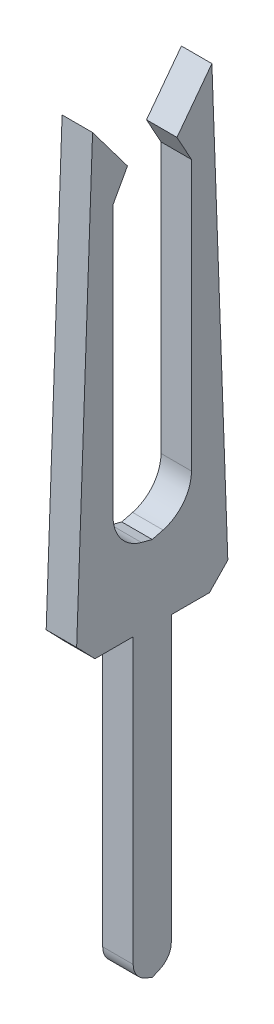
from build123d import *

# Parameters (mm, degrees)
BOSS_EXTRUDE1_DEPTH = 0.4


with BuildPart() as part:
    # Sketch1 → Boss-Extrude1 (new body)
    with BuildSketch(Plane(origin=(0, 0, 0), x_dir=(0, 0, -1), z_dir=(1, 0, 0))):
        with BuildLine():
            Line((-0.486576567, 7.906439428), (-0.277438328, 2.156274237))
            Line((-0.277438328, 2.156274237), (-0.518351631, 1.906439428))
            Line((-0.518351631, 1.906439428), (-1.019947879, 1.906439428))
            Line((-1.019947879, 1.906439428), (-1.019947879, -1.820037787))
            ThreePointArc((-1.019947879, -1.820037787), (-1.060356555, -1.956314993), (-1.168519693, -2.048537947))
            Line((-1.168519693, -2.048537947), (-1.269947879, -2.093560572))
            Line((-1.269947879, -2.093560572), (-1.371376066, -2.048537947))
            ThreePointArc((-1.371376066, -2.048537947), (-1.479539204, -1.956314993), (-1.519947879, -1.820037787))
            Line((-1.519947879, -1.820037787), (-1.519947879, 1.906439428))
            Line((-1.519947879, 1.906439428), (-2.021544128, 1.906439428))
            Line((-2.021544128, 1.906439428), (-2.26245743, 2.156274237))
            Line((-2.26245743, 2.156274237), (-2.053319191, 7.906439428))
            Line((-2.053319191, 7.906439428), (-1.594947879, 7.296916042))
            Line((-1.594947879, 7.296916042), (-1.785118415, 6.950118253))
            Line((-1.785118415, 6.950118253), (-1.785185155, 3.40759606))
            ThreePointArc((-1.785185155, 3.40759606), (-1.681017639, 3.102108908), (-1.411909463, 2.923912215))
            Line((-1.411909463, 2.923912215), (-1.269947879, 2.886717808))
            Line((-1.269947879, 2.886717808), (-1.127986296, 2.923912215))
            ThreePointArc((-1.127986296, 2.923912215), (-0.85887812, 3.102108908), (-0.754710604, 3.40759606))
            Line((-0.754710604, 3.40759606), (-0.754777344, 6.950118253))
            Line((-0.754777344, 6.950118253), (-0.944947879, 7.296916042))
            Line((-0.944947879, 7.296916042), (-0.486576567, 7.906439428))
        make_face()
    extrude(amount=BOSS_EXTRUDE1_DEPTH)


solid = part.part
